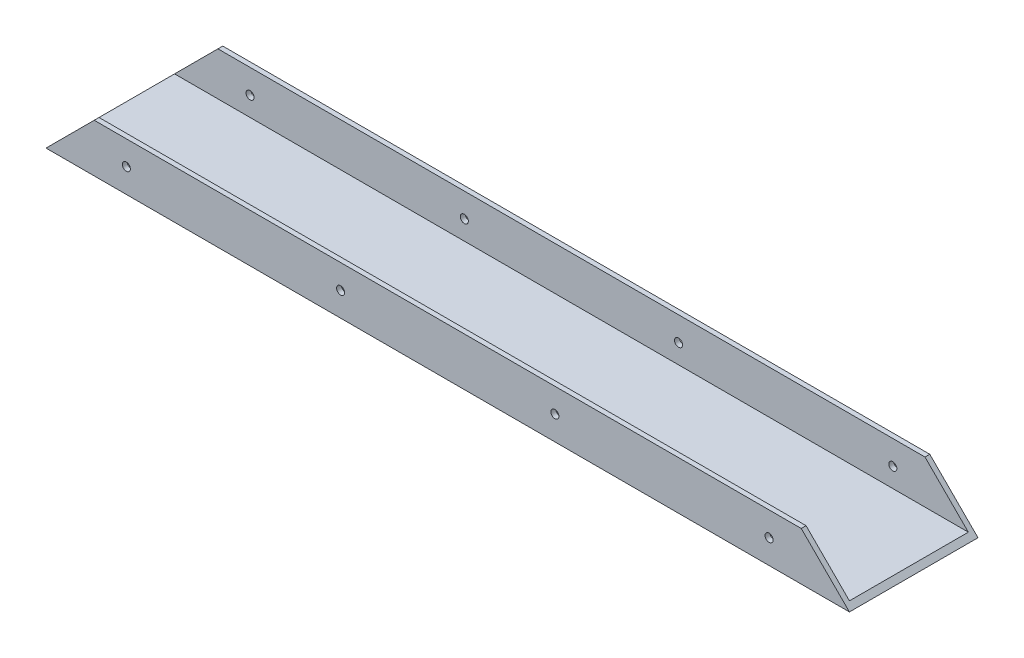
from build123d import *

# Parameters (mm, degrees)
SALIENTE_EXTRUIR1_DEPTH = 250
CROQUIS2_R              = 1.25
CORTAR_EXTRUIR1_DEPTH   = 41


with BuildPart() as part:
    # Croquis1 → Saliente-Extruir1 (new body)
    with BuildSketch(Plane(origin=(0, 0, 0), x_dir=(0, 0, -1), z_dir=(1, 0, 0))):
        Polygon((-20, 0), (20, 0), (20, 15), (18.5, 15), (18.5, 1.5), (-18.5, 1.5), (-18.5, 15), (-20, 15), align=None)
    extrude(amount=SALIENTE_EXTRUIR1_DEPTH)

    # Croquis2 → Cortar-Extruir1 (cut, through all)
    with BuildSketch(Plane(origin=(0, 0, -20), x_dir=(-1, 0, 0), z_dir=(0, 0, -1))):
        with Locations((-225, 7.5)):
            Circle(CROQUIS2_R)
        with Locations((-25, 7.5)):
            Circle(CROQUIS2_R)
        with Locations((-158.333333333, 7.5)):
            Circle(CROQUIS2_R)
        with Locations((-91.666666667, 7.5)):
            Circle(CROQUIS2_R)
        Polygon((0, 15), (-15, 15), (0, 0), align=None)
        Polygon((-250, 15), (-235, 15), (-250, 0), align=None)
    extrude(amount=-CORTAR_EXTRUIR1_DEPTH, mode=Mode.SUBTRACT)


solid = part.part
